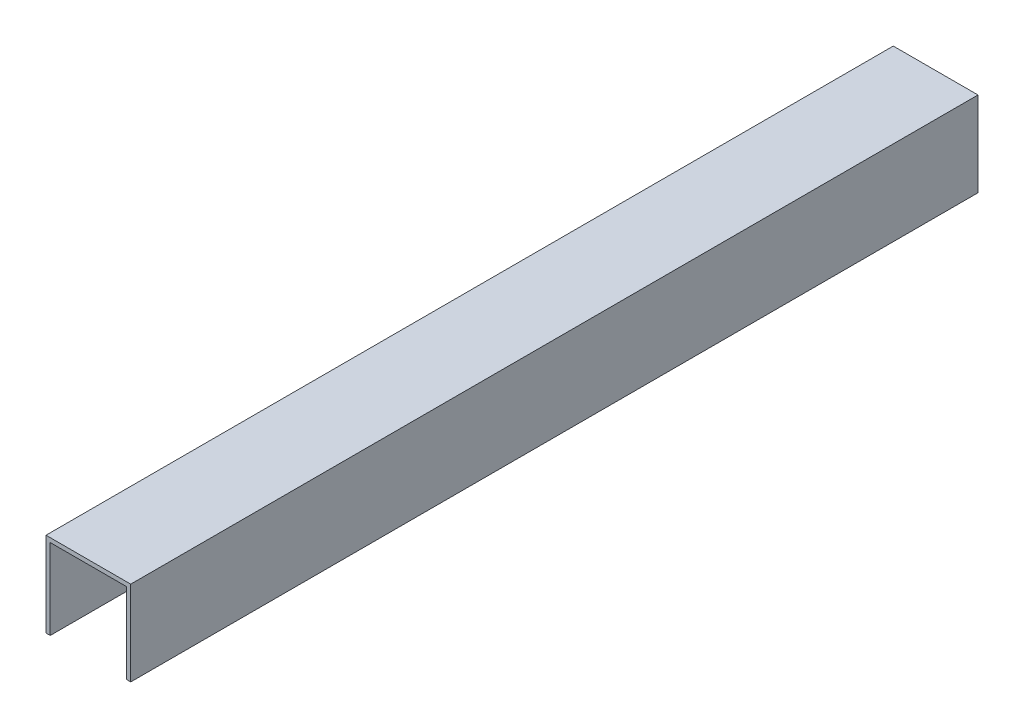
from build123d import *

# Parameters (mm, degrees)
BOSS_EXTRU_1_DEPTH = 100


with BuildPart() as part:
    # Esquisse2 → Boss.-Extru.1 (new body)
    with BuildSketch(Plane.XY):
        Polygon((-107.441493859, -9.233205108), (-107.441493859, 0.766794892), (-97.441493859, 0.766794892), (-97.441493859, -9.233205108), (-97.941493859, -9.233205108), (-97.941493859, 0.266794892), (-106.941493859, 0.266794892), (-106.941493859, -9.233205108), align=None)
    extrude(amount=BOSS_EXTRU_1_DEPTH)


solid = part.part
